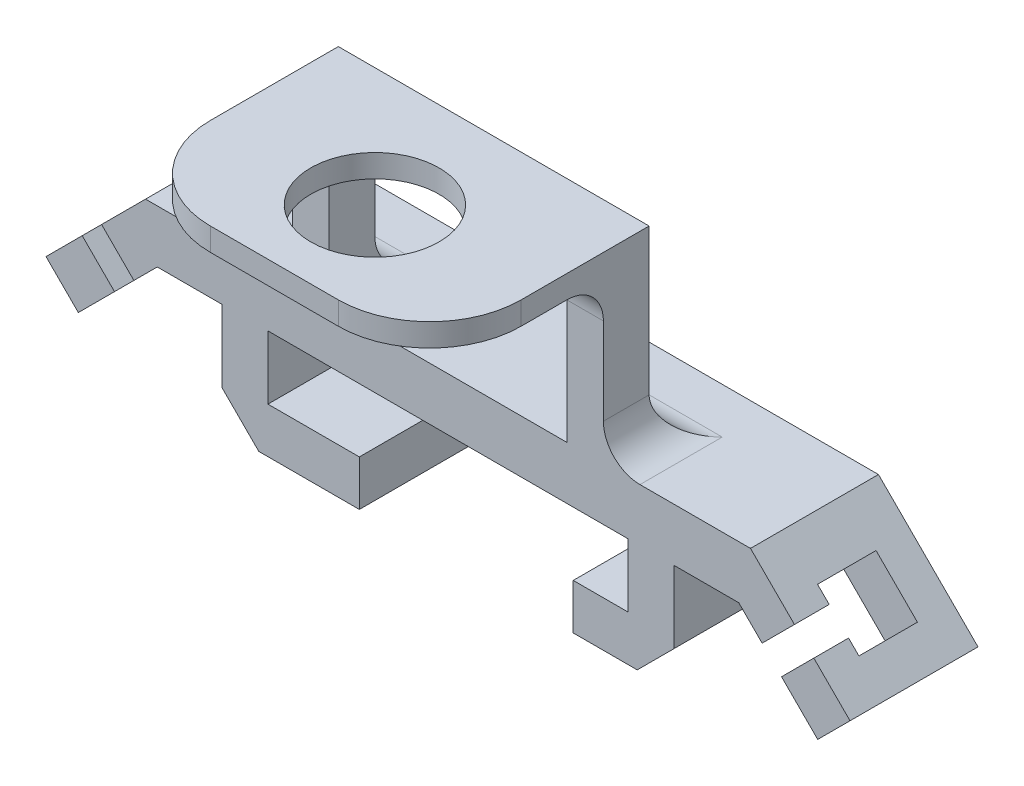
from build123d import *

# Parameters (mm, degrees)
BOSS_EXTRUDE2_DEPTH = 5
BOSS_EXTRUDE3_DEPTH = 2
SKETCH4_W           = 3.2
SKETCH4_H           = 3.2
CUT_EXTRUDE1_DEPTH  = 2.5
SKETCH5_W           = 3.2
SKETCH5_H           = 3.2
CUT_EXTRUDE2_DEPTH  = 2.5
CUT_EXTRUDE4_REACH  = 34.123
CUT_EXTRUDE5_REACH  = 34.123
SKETCH8_W           = 2.5
SKETCH8_H           = 7
BOSS_EXTRUDE4_DEPTH = 5.96
SKETCH10_W          = 7
SKETCH10_H          = 2.49
BOSS_EXTRUDE5_DEPTH = 3
SKETCH11_W          = 7
SKETCH11_H          = 2.49
BOSS_EXTRUDE6_DEPTH = 5
SKETCH12_W          = 17
SKETCH12_H          = 2.5
BOSS_EXTRUDE7_DEPTH = 10
CUT_EXTRUDE7_REACH  = 41.734
SKETCH14_W          = 13
SKETCH14_H          = 8.75
SKETCH16_W          = 17
SKETCH16_H          = 1.25
BOSS_EXTRUDE8_DEPTH = 9.5
CUT_EXTRUDE8_REACH  = 34.394
SKETCH17_R          = 3.51
FILLET7_R           = 2
FILLET8_R           = 5
FILLET9_R           = 5
CHAMFER1_SIZE       = 2
CHAMFER2_SIZE       = 2
FILLET11_R          = 2
FILLET12_R          = 2
FILLET13_R          = 2
FILLET14_R          = 2
FILLET16_R          = 2


with BuildPart() as part:
    # Sketch2 → Boss-Extrude2 (new body)
    with BuildSketch(Plane.XY):
        Polygon((15.905331571, 19.450007488), (-15.905331571, 19.450007488), (-20.223253942, 15.132085117), (-21.991020895, 16.89985207), (-16.54629868, 22.344574285), (16.54629868, 22.344574285), (21.991020895, 16.89985207), (20.223253942, 15.132085117), align=None)
    extrude(amount=BOSS_EXTRUDE2_DEPTH)

    # Sketch2_2 → Boss-Extrude3 (add)
    with BuildSketch(Plane.XY):
        Polygon((15.905331571, 19.450007488), (-15.905331571, 19.450007488), (-20.223253942, 15.132085117), (-21.991020895, 16.89985207), (-16.54629868, 22.344574285), (16.54629868, 22.344574285), (21.991020895, 16.89985207), (20.223253942, 15.132085117), align=None)
    extrude(amount=-BOSS_EXTRUDE3_DEPTH)

    # Sketch4 → Cut-Extrude1 (cut)
    with BuildSketch(Plane(origin=(19.445436483, 19.445436483, 0), x_dir=(0.7071067811865479, -0.7071067811865471, 0), z_dir=(0.7071067811865471, 0.7071067811865479, 0))):
        with Locations((0, -1.5)):
            Rectangle(SKETCH4_W, SKETCH4_H)
    extrude(amount=-CUT_EXTRUDE1_DEPTH, mode=Mode.SUBTRACT)

    # Sketch5 → Cut-Extrude2 (cut)
    with BuildSketch(Plane(origin=(-19.445436483, 19.445436483, 0), x_dir=(0, 0, 1), z_dir=(-0.7071067811865477, 0.7071067811865475, 0))):
        with Locations((1.5, 0)):
            Rectangle(SKETCH5_W, SKETCH5_H)
    extrude(amount=-CUT_EXTRUDE2_DEPTH, mode=Mode.SUBTRACT)

    # Sketch6 → Cut-Extrude4 (cut, up to next)
    with BuildSketch(Plane.XY.offset(5), mode=Mode.PRIVATE) as cut_extrude4_sk1:
        Polygon((-20.011121908, 18.879751058), (-18.950461736, 19.940411229), (-17.182694783, 18.172644276), (-18.243354955, 17.111984105), align=None)
    cut_extrude4_tool1 = extrude(cut_extrude4_sk1.sketch, amount=-CUT_EXTRUDE4_REACH, mode=Mode.PRIVATE) & part.part
    add(cut_extrude4_tool1.solids().sort_by_distance((-18.596908, 18.526198, 5))[0], mode=Mode.SUBTRACT)

    # Sketch7 → Cut-Extrude5 (cut, up to next)
    with BuildSketch(Plane.XY.offset(5), mode=Mode.PRIVATE) as cut_extrude5_sk1:
        Polygon((17.182694783, 18.172644276), (18.950461736, 19.940411229), (20.011121908, 18.879751058), (18.243354955, 17.111984105), align=None)
    cut_extrude5_tool1 = extrude(cut_extrude5_sk1.sketch, amount=-CUT_EXTRUDE5_REACH, mode=Mode.PRIVATE) & part.part
    add(cut_extrude5_tool1.solids().sort_by_distance((18.596908, 18.526198, 5))[0], mode=Mode.SUBTRACT)

    # Sketch8 → Boss-Extrude4 (add)
    with BuildSketch(Plane(origin=(0, 19.450007488, 0), x_dir=(-1, 0, 0), z_dir=(0, -1, 0))):
        with Locations((11.1, -1.5)):
            Rectangle(SKETCH8_W, SKETCH8_H)
        with Locations((-11.1, -1.5)):
            Rectangle(SKETCH8_W, SKETCH8_H)
    extrude(amount=BOSS_EXTRUDE4_DEPTH)

    # Sketch10 → Boss-Extrude5 (add)
    with BuildSketch(Plane.ZY.offset(-9.85)):
        with Locations((1.5, 14.735007488)):
            Rectangle(SKETCH10_W, SKETCH10_H)
    extrude(amount=BOSS_EXTRUDE5_DEPTH)

    # Sketch11 → Boss-Extrude6 (add)
    with BuildSketch(Plane(origin=(-9.85, 0, 0), x_dir=(0, 0, -1), z_dir=(1, 0, 0))):
        with Locations((-1.5, 14.735007488)):
            Rectangle(SKETCH11_W, SKETCH11_H)
    extrude(amount=BOSS_EXTRUDE6_DEPTH)

    # Sketch12 → Boss-Extrude7 (add)
    with BuildSketch(Plane(origin=(0, 22.344574285, 0), x_dir=(1, 0, 0), z_dir=(0, 1, 0))):
        with Locations((0, -3.75)):
            Rectangle(SKETCH12_W, SKETCH12_H)
    extrude(amount=BOSS_EXTRUDE7_DEPTH)

    # Sketch14 → Cut-Extrude7 (cut, up to next)
    with BuildSketch(Plane.XY.offset(5), mode=Mode.PRIVATE) as cut_extrude7_sk1:
        with Locations((0, 26.719574285)):
            Rectangle(SKETCH14_W, SKETCH14_H)
    cut_extrude7_tool1 = extrude(cut_extrude7_sk1.sketch, amount=-CUT_EXTRUDE7_REACH, mode=Mode.PRIVATE) & part.part
    add(cut_extrude7_tool1.solids().sort_by_distance((0, 26.719574, 5))[0], mode=Mode.SUBTRACT)

    # Sketch16 → Boss-Extrude8 (add)
    with BuildSketch(Plane.XY.offset(5)):
        with Locations((0, 31.719574285)):
            Rectangle(SKETCH16_W, SKETCH16_H)
    extrude(amount=BOSS_EXTRUDE8_DEPTH)

    # Sketch17 → Cut-Extrude8 (cut, up to next)
    with BuildSketch(Plane(origin=(0, 32.344574285, 0), x_dir=(1, 0, 0), z_dir=(0, 1, 0)), mode=Mode.PRIVATE) as cut_extrude8_sk1:
        with Locations((0, -9)):
            Circle(SKETCH17_R)
    cut_extrude8_tool1 = extrude(cut_extrude8_sk1.sketch, amount=-CUT_EXTRUDE8_REACH, mode=Mode.PRIVATE) & part.part
    add(cut_extrude8_tool1.solids().sort_by_distance((0, 32.344574, 9))[0], mode=Mode.SUBTRACT)

    # Fillet7
    fillet7_edges = [part.edges().sort_by_distance(p)[0] for p in [
        (7.5, 31.094574285, 5),
    ]]
    fillet(fillet7_edges, radius=FILLET7_R)

    # Fillet8
    fillet8_edges = [part.edges().sort_by_distance(p)[0] for p in [
        (8.5, 31.719574285, 14.5),
    ]]
    fillet(fillet8_edges, radius=FILLET8_R)

    # Fillet9
    fillet9_edges = [part.edges().sort_by_distance(p)[0] for p in [
        (-8.5, 31.719574285, 14.5),
    ]]
    fillet(fillet9_edges, radius=FILLET9_R)

    # Chamfer1
    chamfer1_edges = [part.edges().sort_by_distance(p)[0] for p in [
        (-12.35, 13.490007488, 1.5),
    ]]
    chamfer(chamfer1_edges, length=CHAMFER1_SIZE)

    # Chamfer2
    chamfer2_edges = [part.edges().sort_by_distance(p)[0] for p in [
        (12.35, 13.490007488, 1.5),
    ]]
    chamfer(chamfer2_edges, length=CHAMFER2_SIZE)

    # Fillet11
    fillet11_edges = [part.edges().sort_by_distance(p)[0] for p in [
        (-8.5, 22.344574285, 3.75),
    ]]
    fillet(fillet11_edges, radius=FILLET11_R)

    # Fillet12
    fillet12_edges = [part.edges().sort_by_distance(p)[0] for p in [
        (8.5, 22.344574285, 3.75),
    ]]
    fillet(fillet12_edges, radius=FILLET12_R)

    # Fillet13
    fillet13_edges = [part.edges().sort_by_distance(p)[0] for p in [
        (8.5, 22.344574285, 2.5),
    ]]
    fillet(fillet13_edges, radius=FILLET13_R)

    # Fillet14
    fillet14_edges = [part.edges().sort_by_distance(p)[0] for p in [
        (-8.5, 22.344574285, 2.5),
    ]]
    fillet(fillet14_edges, radius=FILLET14_R)

    # Fillet16
    fillet16_edges = [part.edges().sort_by_distance(p)[0] for p in [
        (-7.5, 31.094574285, 5),
    ]]
    fillet(fillet16_edges, radius=FILLET16_R)


solid = part.part
